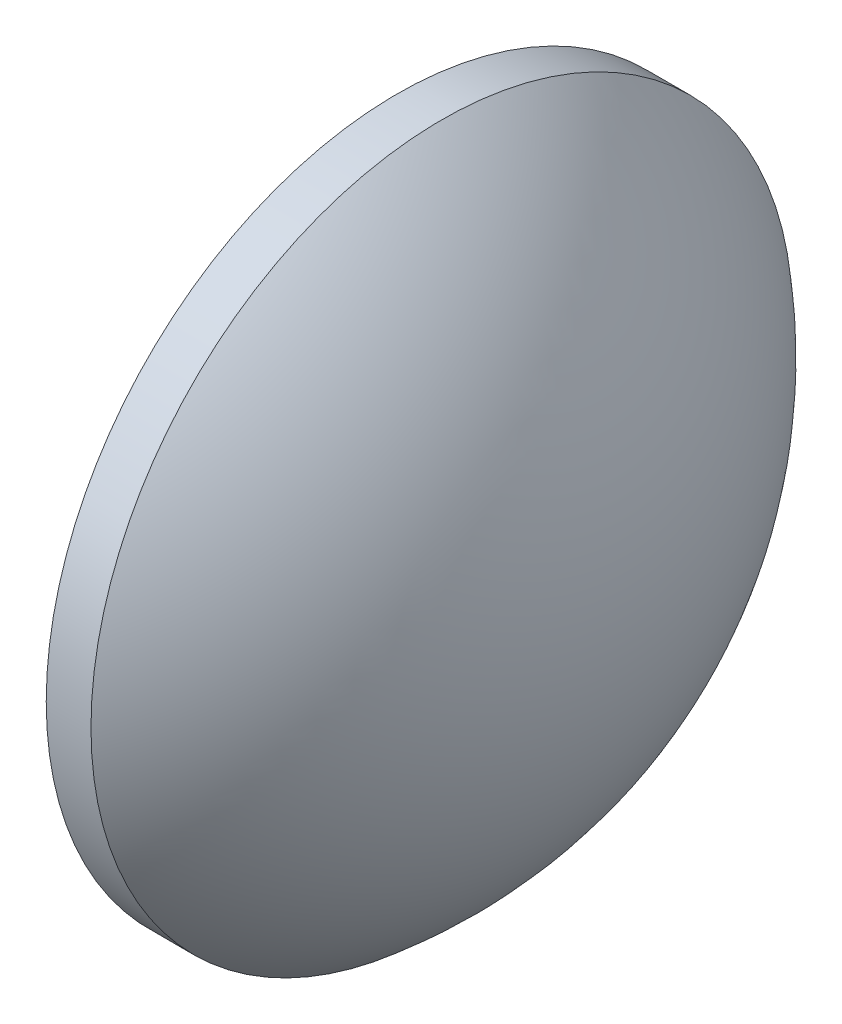
from build123d import *


with BuildPart() as part:
    # 草图1 → 旋转1 (revolve)
    with BuildSketch(Plane.XY, mode=Mode.PRIVATE) as revolve_1_sk:
        with BuildLine():
            Line((377.012173506, -7.833785246), (377.012173506, 0.166214754))
            Line((377.012173506, 0.166214754), (378.032173506, 0.166214754))
            ThreePointArc((378.032173506, 0.166214754), (380.819605503, -3.409748628), (381.812173506, -7.833785246))
            Line((381.812173506, -7.833785246), (377.012173506, -7.833785246))
        make_face()
    revolve(revolve_1_sk.sketch.rotate(Axis((375.364201033, -7.833785246, 0), (1, 0, 0)), 180), axis=Axis((375.364201033, -7.833785246, 0), (1, 0, 0)))  # turned: the seam where the file's is


solid = part.part
